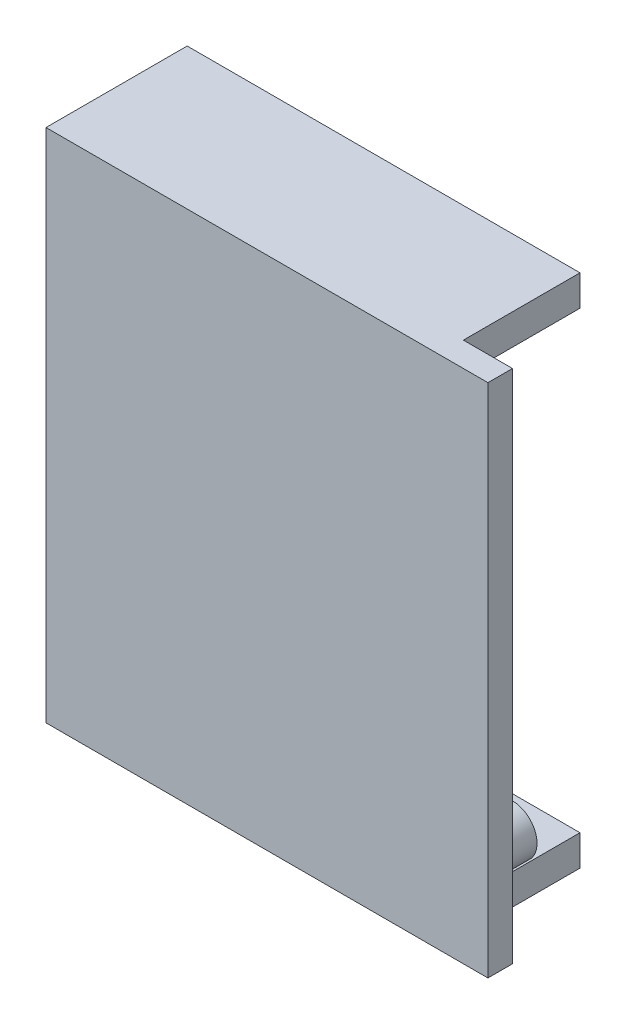
from build123d import *

# Parameters (mm, degrees)
SKETCH_1_W          = 36
SKETCH_1_H          = 42
EXTRUDE_1_DEPTH     = 2
SKETCH_2_W          = 32
SKETCH_2_H          = 2.5
EXTRUDE_2_DEPTH     = 9.5
SKETCH_3_W          = 3
SKETCH_3_H          = 39.5
CUT_EXTRUDE_1_DEPTH = 1
SKETCH_4_R          = 2
SKETCH_4_R_2        = 1.1
EXTRUDE_3_DEPTH     = 4
SKETCH_4_2_R        = 2
EXTRUDE_4_DEPTH     = 1
EXTRUDE_5_DEPTH     = 4
EXTRUDE_6_DEPTH     = 4
SKETCH_8_R          = 2.5
EXTRUDE_7_DEPTH     = 4
SKETCH_9_W          = 9.5
SKETCH_9_H          = 1.5
EXTRUDE_8_DEPTH     = 4


with BuildPart() as part:
    # 草图1 → 凸台-拉伸1 (new body)
    with BuildSketch(Plane.XY):
        with Locations((-3, 0)):
            Rectangle(SKETCH_1_W, SKETCH_1_H)
    extrude(amount=EXTRUDE_1_DEPTH)

    # 草图2 → 凸台-拉伸2 (add)
    with BuildSketch(Plane(origin=(0, 0, 0), x_dir=(-1, 0, 0), z_dir=(0, 0, -1))):
        with Locations((5, 19.75)):
            Rectangle(SKETCH_2_W, SKETCH_2_H)
        with Locations((5, -19.75)):
            Rectangle(SKETCH_2_W, SKETCH_2_H)
    extrude(amount=EXTRUDE_2_DEPTH)

    # 草图3 → 切除-拉伸1 (cut)
    with BuildSketch(Plane(origin=(0, 0, 0), x_dir=(-1, 0, 0), z_dir=(0, 0, -1))):
        with Locations((-12.5, 0)):
            Rectangle(SKETCH_3_W, SKETCH_3_H)
    extrude(amount=-CUT_EXTRUDE_1_DEPTH, mode=Mode.SUBTRACT)

    # 草图4 → 凸台-拉伸3 (add)
    with BuildSketch(Plane(origin=(0, 0, 0), x_dir=(-1, 0, 0), z_dir=(0, 0, -1))):
        with Locations((11, 15.5)):
            Circle(SKETCH_4_R)
        with Locations((11, 15.5)):
            Circle(SKETCH_4_R_2, mode=Mode.SUBTRACT)
        with Locations((-11, -15.5)):
            Circle(SKETCH_4_R)
        with Locations((-11, -15.5)):
            Circle(SKETCH_4_R_2, mode=Mode.SUBTRACT)
    extrude(amount=EXTRUDE_3_DEPTH)

    # 草图4<2> → 凸台-拉伸4 (add)
    with BuildSketch(Plane(origin=(0, 0, 0), x_dir=(-1, 0, 0), z_dir=(0, 0, -1))):
        with Locations((-11, -15.5)):
            Circle(SKETCH_4_2_R)
    extrude(amount=-EXTRUDE_4_DEPTH)

    # 草图5 → 凸台-拉伸5 (add)
    with BuildSketch(Plane(origin=(0, 0, 0), x_dir=(-1, 0, 0), z_dir=(0, 0, -1))):
        Polygon((9, 15.5), (9, 18.5), (13, 18.5), (13, 15.5), (11, 17.5), align=None)
    extrude(amount=EXTRUDE_5_DEPTH)

    # 草图6 → 凸台-拉伸6 (add)
    with BuildSketch(Plane(origin=(0, 0, 0), x_dir=(-1, 0, 0), z_dir=(0, 0, -1))):
        Polygon((-11, -17.5), (-11, -18.5), (-9, -18.5), (-9, -15.5), align=None)
    extrude(amount=EXTRUDE_6_DEPTH)

    # 草图8 → 凸台-拉伸7 (add)
    with BuildSketch(Plane(origin=(0, 0, 0), x_dir=(-1, 0, 0), z_dir=(0, 0, -1))):
        with Locations((7.5, -12.5)):
            Circle(SKETCH_8_R)
        with Locations((-7.5, 12.5)):
            Circle(SKETCH_8_R)
    extrude(amount=EXTRUDE_7_DEPTH)

    # 草图9 → 凸台-拉伸8 (add)
    with BuildSketch(Plane.ZY.offset(21)):
        with Locations((-4.75, -17.75)):
            Rectangle(SKETCH_9_W, SKETCH_9_H)
        with Locations((-4.75, 17.75)):
            Rectangle(SKETCH_9_W, SKETCH_9_H)
    extrude(amount=-EXTRUDE_8_DEPTH)


solid = part.part
